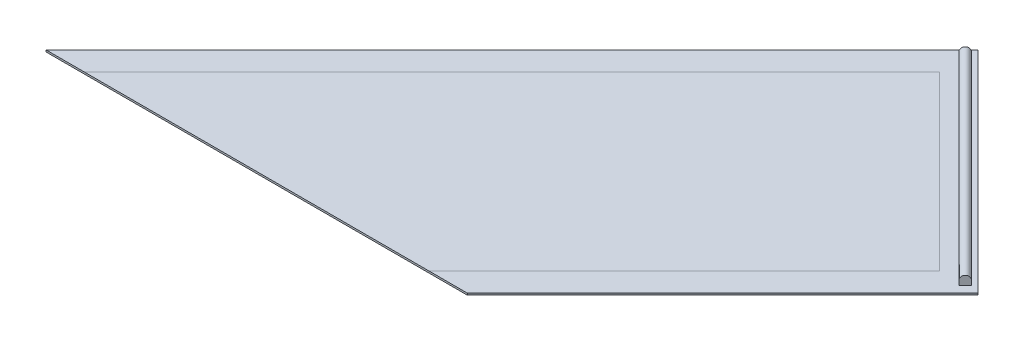
from build123d import *

# Parameters (mm, degrees)
BOSS_EXTRUDE1_DEPTH = 2
BOSS_EXTRUDE2_DEPTH = 10
CUT_EXTRUDE1_REACH  = 522
BOSS_EXTRUDE3_DEPTH = 2


with BuildPart() as part:
    # Sketch1 → Boss-Extrude1 (new body)
    with BuildSketch(Plane(origin=(0, 0, 0), x_dir=(1, 0, 0), z_dir=(0, 1, 0))):
        Polygon((-49.497474683, -516.187950266), (233.345237792, -233.345237792), (0, 0), (-282.842712475, -282.842712475), align=None)
    extrude(amount=BOSS_EXTRUDE1_DEPTH)

    # Sketch4 → Boss-Extrude2 (add)
    with BuildSketch(Plane(origin=(0, 2, 0), x_dir=(1, 0, 0), z_dir=(0, 1, 0))):
        Polygon((3.535533906, -10.606601718), (-3.535533906, -17.67766953), (215.667568262, -236.880771697), (222.738636074, -229.809703886), align=None)
    extrude(amount=BOSS_EXTRUDE2_DEPTH)

    # Sketch6 → Cut-Extrude1 (cut, up to next)
    with BuildSketch(Plane(origin=(7.071067812, 0, 7.071067812), x_dir=(-0.707106781, 0, 0.707106781), z_dir=(-0.707106781, 0, -0.707106781)), mode=Mode.PRIVATE) as cut_extrude1_sk1:
        with BuildLine():
            Line((5, 12), (5, 7))
            ThreePointArc((5, 7), (6.464466094, 10.535533906), (10, 12))
            Line((10, 12), (5, 12))
        make_face()
    cut_extrude1_tool1 = extrude(cut_extrude1_sk1.sketch, amount=-CUT_EXTRUDE1_REACH, mode=Mode.PRIVATE) & part.part
    add(cut_extrude1_tool1.solids().sort_by_distance((2.745809, 10.88316, 11.396327))[0], mode=Mode.SUBTRACT)
    # Sketch6 → Cut-Extrude1 (cut, up to next)
    with BuildSketch(Plane(origin=(7.071067812, 0, 7.071067812), x_dir=(-0.707106781, 0, 0.707106781), z_dir=(-0.707106781, 0, -0.707106781)), mode=Mode.PRIVATE) as cut_extrude1_sk2:
        with BuildLine():
            Line((15, 12), (10, 12))
            ThreePointArc((10, 12), (13.535533906, 10.535533906), (15, 7))
            Line((15, 7), (15, 12))
        make_face()
    cut_extrude1_tool2 = extrude(cut_extrude1_sk2.sketch, amount=-CUT_EXTRUDE1_REACH, mode=Mode.PRIVATE) & part.part
    add(cut_extrude1_tool2.solids().sort_by_distance((-2.745809, 10.88316, 16.887945))[0], mode=Mode.SUBTRACT)

    # Sketch10 → Boss-Extrude3 (add)
    with BuildSketch(Plane(origin=(0, 0, 0), x_dir=(1, 0, 0), z_dir=(0, 1, 0))):
        Polygon((-282.842712475, -282.842712475), (-516.187950266, -516.187950266), (-49.497474683, -516.187950266), align=None)
    extrude(amount=BOSS_EXTRUDE3_DEPTH)


solid = part.part
